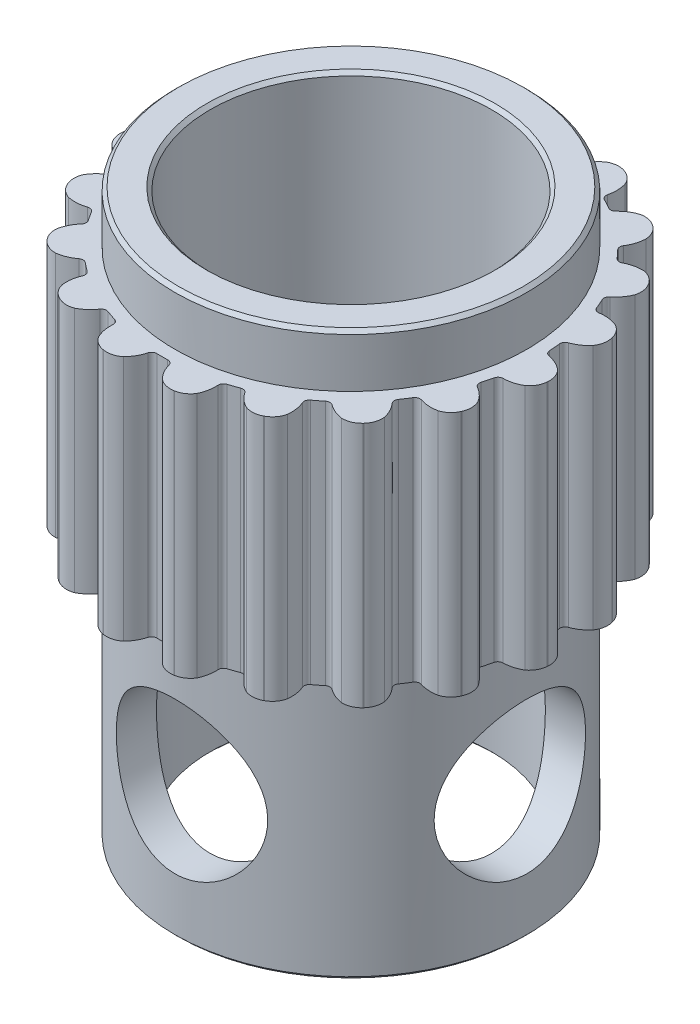
from build123d import *

# Parameters (mm, degrees)
BODYS_W                = 2.11
BODYS_H                = 7
GT2PROFILE_DEPTH       = 3.5
GT2_GROOVE_CP_COUNT    = 19
TOPWALLS_R             = 5
TOPWALLS_R_2           = 4
TOPWALL_DEPTH          = 1.5
BOTTOMWALLS_R          = 5
BOTTOMWALLS_R_2        = 4
BOTTOMWALL_DEPTH       = 7.5
CLEARANCE_HOLE1_REACH  = 18.779
CLEARANCE_HOLE1_BORE_R = 2.15
CIRPATTERN1_COUNT      = 2
CIRPATTERN1_ANGLE      = 90
INNERC_SIZE            = 0.1
OUTERC_SIZE            = 0.1


with BuildPart() as part:
    # BodyS → Body (revolve)
    with BuildSketch(Plane.XY, mode=Mode.PRIVATE) as body_sk:
        with Locations((5.055, 0)):
            Rectangle(BODYS_W, BODYS_H)
    revolve(body_sk.sketch.rotate(Axis((0, 3.5, 0), (0, -1, 0)), 90), axis=Axis((0, 3.5, 0), (0, -1, 0)))

    # GT2ProfileS → GT2Profile (cut, symmetric)
    with BuildSketch(Plane(origin=(0, 0, 0), x_dir=(1, 0, 0), z_dir=(0, 1, 0))):
        with BuildLine():
            ThreePointArc((0.299749921, -5.468781955), (0.244461347, -5.387479579), (0.150701934, -5.357881011))
            ThreePointArc((0.150701934, -5.357881011), (0, -5.36), (-0.150701934, -5.357881011))
            ThreePointArc((-0.150701934, -5.357881011), (-0.244461347, -5.387479579), (-0.299749921, -5.468781955))
            ThreePointArc((-0.299749921, -5.468781955), (-0.396626607, -5.703924717), (-0.549685833, -5.907025885))
            ThreePointArc((-0.549685833, -5.907025885), (-0.7593874, -6.016293358), (-0.995541542, -6.028349446))
            ThreePointArc((-0.995541542, -6.028349446), (0, -6.11), (0.995541542, -6.028349446))
            ThreePointArc((0.995541542, -6.028349446), (0.7593874, -6.016293358), (0.549685833, -5.907025885))
            ThreePointArc((0.549685833, -5.907025885), (0.396626607, -5.703924717), (0.299749921, -5.468781955))
        make_face()
    gt2profile = extrude(amount=GT2PROFILE_DEPTH, both=True, mode=Mode.SUBTRACT)

    # GT2 Groove CP: GT2Profile ×19 about axis
    gt2_groove_cp_axis = Axis((0, 0, 0), (0, 1, 0))
    for i in range(1, GT2_GROOVE_CP_COUNT):
        add(gt2profile.rotate(gt2_groove_cp_axis, i * 360 / GT2_GROOVE_CP_COUNT), mode=Mode.SUBTRACT)

    # TopWallS → TopWall (add)
    with BuildSketch(Plane(origin=(0, 3.5, 0), x_dir=(1, 0, 0), z_dir=(0, 1, 0))):
        with Locations(Location((0, 0, 0), (0, 0, 90))):
            Circle(TOPWALLS_R)
        with Locations(Location((0, 0, 0), (0, 0, 270))):
            Circle(TOPWALLS_R_2, mode=Mode.SUBTRACT)
    extrude(amount=TOPWALL_DEPTH)

    # BottomWallS → BottomWall (add)
    with BuildSketch(Plane(origin=(0, -3.5, 0), x_dir=(-1, 0, 0), z_dir=(0, -1, 0))):
        with Locations(Location((0, 0, 0), (0, 0, 90))):
            Circle(BOTTOMWALLS_R)
        with Locations(Location((0, 0, 0), (0, 0, 270))):
            Circle(BOTTOMWALLS_R_2, mode=Mode.SUBTRACT)
    extrude(amount=BOTTOMWALL_DEPTH)

    # Clearance Hole1 bore → Clearance Hole1 (cut, up to next)
    with BuildSketch(Plane.XY.offset(5), mode=Mode.PRIVATE) as clearance_hole1_sk1:
        with Locations((0, -7.25)):
            Circle(CLEARANCE_HOLE1_BORE_R)
    clearance_hole1_tool1 = extrude(clearance_hole1_sk1.sketch, amount=-CLEARANCE_HOLE1_REACH, mode=Mode.PRIVATE) & part.part
    clearance_hole1 = clearance_hole1_tool1.solids().sort_by_distance((0, -7.25, 5))[0]
    add(clearance_hole1, mode=Mode.SUBTRACT)

    # CirPattern1: Clearance Hole1 ×2 about axis
    cirpattern1_axis = Axis((0, -11, 0), (0, 1, 0))
    for i in range(1, CIRPATTERN1_COUNT):
        add(clearance_hole1.rotate(cirpattern1_axis, i * CIRPATTERN1_ANGLE / (CIRPATTERN1_COUNT - 1)), mode=Mode.SUBTRACT)

    # InnerC
    innerc_edges = [part.edges().sort_by_distance(p)[0] for p in [
        (0, 5, -4),
        (0, -11, -4),
    ]]
    chamfer(innerc_edges, length=INNERC_SIZE)

    # OuterC
    outerc_edges = [part.edges().sort_by_distance(p)[0] for p in [
        (0, 5, 5),
        (0, -11, 5),
    ]]
    chamfer(outerc_edges, length=OUTERC_SIZE)


solid = part.part
